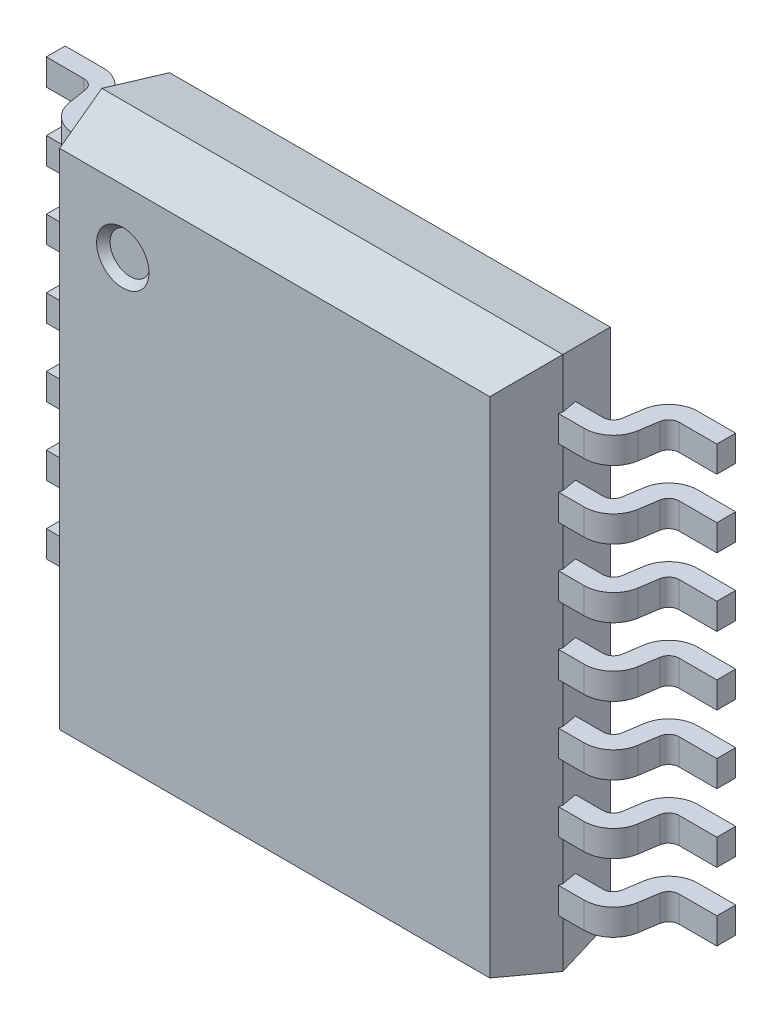
from build123d import *

# Parameters (mm, degrees)
EXTRUDE_START             = 0.65
SKETCH_1_W                = 4.4
SKETCH_1_H                = 5.1
EXTRUDE_1_DEPTH           = 0.55
EXTRUDE_1_TAPER           = 15
EXTRUDE_1_OTHER_WAY_DEPTH = 0.55
EXTRUDE_1_OTHER_WAY_TAPER = 10
EXTRUDE_START_2           = 2.075
EXTRUDE_2_DEPTH           = 0.25
EXTRUDE_2_2_DEPTH         = 0.25
SKETCH_2_R                = 0.25
CUT_EXTRUDE_3_DEPTH       = 0.07
CUT_EXTRUDE_3_TAPER       = 40
PATTERN_LINEAR_1_COUNT    = 7
PATTERN_LINEAR_1_PITCH    = 0.65


with BuildPart() as part:
    # Эскиз1 → Вытянуть1 (new body)
    with BuildSketch(Plane.XY.offset(EXTRUDE_START)):
        Rectangle(SKETCH_1_W, SKETCH_1_H)
    extrude(amount=EXTRUDE_1_DEPTH, taper=EXTRUDE_1_TAPER)

    # Эскиз1 → Вытянуть1 other way (add)
    with BuildSketch(Plane.XY.offset(EXTRUDE_START)):
        Rectangle(SKETCH_1_W, SKETCH_1_H)
    extrude(amount=-EXTRUDE_1_OTHER_WAY_DEPTH, taper=EXTRUDE_1_OTHER_WAY_TAPER)

    # Эскиз2 → Вытянуть3 (cut)
    with BuildSketch(Plane.XY.offset(1.2)):
        with Locations((-1.45, 1.8)):
            Circle(SKETCH_2_R)
    extrude(amount=-CUT_EXTRUDE_3_DEPTH, taper=CUT_EXTRUDE_3_TAPER, mode=Mode.SUBTRACT)


with BuildPart() as body_2:
    # Эскиз3 → Вытянуть2 (new body)
    with BuildSketch(Plane(origin=(0, 0, 0), x_dir=(1, 0, 0), z_dir=(0, 1, 0)).offset(EXTRUDE_START_2)):
        with BuildLine():
            Line((2.53538102, -0.418737885), (2.56343731, -0.237227898))
            ThreePointArc((2.56343731, -0.237227898), (2.657909807, -0.067425086), (2.840151146, 0))
            Line((2.840151146, 0), (3.2, 0))
            Line((3.2, 0), (3.2, -0.18))
            Line((3.2, -0.18), (2.840151146, -0.18))
            ThreePointArc((2.840151146, -0.18), (2.775064954, -0.204080388), (2.741324776, -0.264724249))
            Line((2.741324776, -0.264724249), (2.713268487, -0.446234236))
            ThreePointArc((2.713268487, -0.446234236), (2.618795989, -0.616037048), (2.43655465, -0.683462134))
            Line((2.43655465, -0.683462134), (2.090093463, -0.683462134))
            Line((2.090093463, -0.683462134), (2.090093463, -0.503462134))
            Line((2.090093463, -0.503462134), (2.43655465, -0.503462134))
            ThreePointArc((2.43655465, -0.503462134), (2.501640843, -0.479381746), (2.53538102, -0.418737885))
        make_face()
    extrude_2 = extrude(amount=-EXTRUDE_2_DEPTH)


with BuildPart() as body_3:
    # Эскиз3 → Extrude 2 2 (new body)
    with BuildSketch(Plane(origin=(0, 0, 0), x_dir=(1, 0, 0), z_dir=(0, 1, 0)).offset(EXTRUDE_START_2)):
        with BuildLine():
            Line((-2.090093463, -0.503462134), (-2.43655465, -0.503462134))
            ThreePointArc((-2.43655465, -0.503462134), (-2.501640843, -0.479381746), (-2.53538102, -0.418737885))
            Line((-2.53538102, -0.418737885), (-2.56343731, -0.237227898))
            ThreePointArc((-2.56343731, -0.237227898), (-2.657909807, -0.067425086), (-2.840151146, 0))
            Line((-2.840151146, 0), (-3.2, 0))
            Line((-3.2, 0), (-3.2, -0.18))
            Line((-3.2, -0.18), (-2.840151146, -0.18))
            ThreePointArc((-2.840151146, -0.18), (-2.775064954, -0.204080388), (-2.741324776, -0.264724249))
            Line((-2.741324776, -0.264724249), (-2.713268487, -0.446234236))
            ThreePointArc((-2.713268487, -0.446234236), (-2.618795989, -0.616037048), (-2.43655465, -0.683462134))
            Line((-2.43655465, -0.683462134), (-2.090093463, -0.683462134))
            Line((-2.090093463, -0.683462134), (-2.090093463, -0.503462134))
        make_face()
    extrude_2_2 = extrude(amount=-EXTRUDE_2_2_DEPTH)


with BuildPart() as part_1:
    add(part.part)

    # Линейный массив1: Вытянуть2, Extrude 2 2 ×7
    with Locations(*[(0, -i * PATTERN_LINEAR_1_PITCH, 0) for i in range(1, PATTERN_LINEAR_1_COUNT)]):
        add(extrude_2)
        add(extrude_2_2)


solid = Compound([body_2.part, body_3.part, part_1.part])
